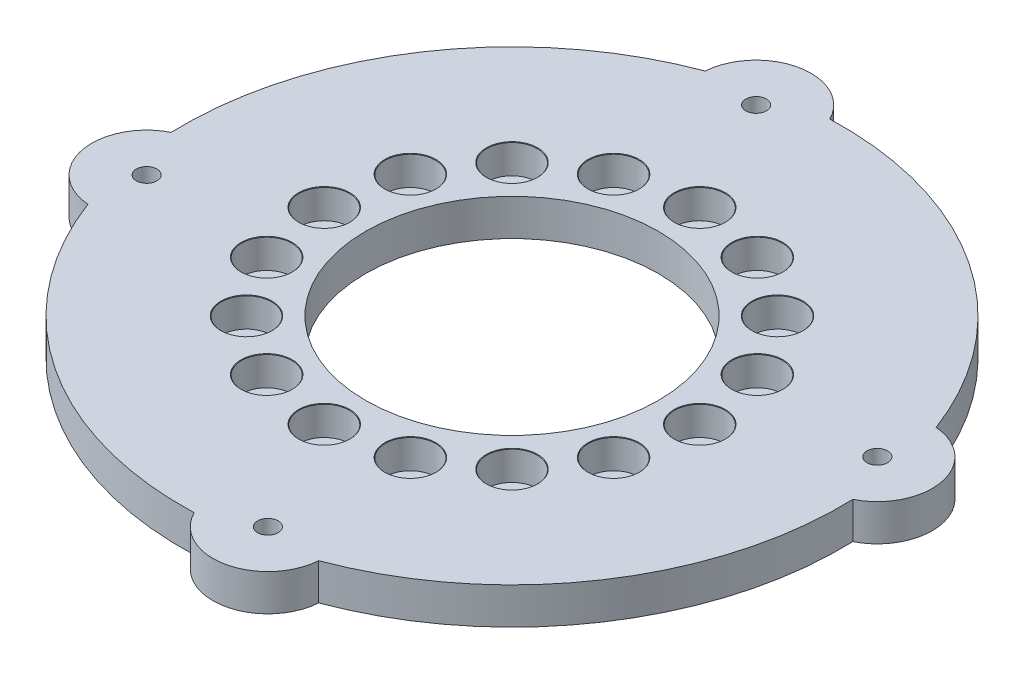
from build123d import *

# Parameters (mm, degrees)
SKETCH1_W                                            = 63.5
SKETCH1_H                                            = 12.7
CIRPATTERN1_COUNT                                    = 16
SKETCH24_R                                           = 19.05
BOSS_EXTRUDE1_DEPTH                                  = 12.7
CBORE_FOR_1_4_BINDING_HEAD_MACHINE_SCREW_D           = 7.14248
CBORE_FOR_1_4_BINDING_HEAD_MACHINE_SCREW_CBORE_D     = 14.2875
CBORE_FOR_1_4_BINDING_HEAD_MACHINE_SCREW_CBORE_DEPTH = 4.191


with BuildPart() as part:
    # Sketch1 → Revolve1 (revolve)
    with BuildSketch(Plane.XY):
        with Locations((82.55, 6.35)):
            Rectangle(SKETCH1_W, SKETCH1_H)
    revolve(axis=Axis((0, 58.205419954, 0), (0, -1, 0)))

    # Sketch20 → CBORE for 5_16 Binding Head Machine Scre (revolve, cut)
    with BuildSketch(Plane(origin=(65.1256, 12.7, 0), x_dir=(0, 0, 1), z_dir=(1, 0, 0))):
        Polygon((0, 0), (0, 12.7), (4.2164, 12.7), (4.2164, 10.16), (8.73125, 10.16), (8.73125, 0.15875), (8.89, 0), align=None)
    cbore_for_5_16_binding_head_machine_scre = revolve(axis=Axis((65.1256, 19.05, 0), (0, -1, 0)), mode=Mode.SUBTRACT)

    # CirPattern1: CBORE for 5_16 Binding Head Machine Scre ×16 about axis
    cirpattern1_axis = Axis((0, 58.205419954, 0), (0, -1, 0))
    for i in range(1, CIRPATTERN1_COUNT):
        add(cbore_for_5_16_binding_head_machine_scre.rotate(cirpattern1_axis, i * 360 / CIRPATTERN1_COUNT), mode=Mode.SUBTRACT)

    # Sketch24 → Boss-Extrude1 (add)
    with BuildSketch(Plane(origin=(0, 12.7, 0), x_dir=(1, 0, 0), z_dir=(0, 1, 0))):
        with Locations((-21.023532701, 105.692436214)):
            Circle(SKETCH24_R)
        with Locations((105.692436214, 21.023532701)):
            Circle(SKETCH24_R)
        with Locations((-105.692436214, -21.023532701)):
            Circle(SKETCH24_R)
        with Locations((21.023532701, -105.692436214)):
            Circle(SKETCH24_R)
    extrude(amount=-BOSS_EXTRUDE1_DEPTH)

    # CBORE for 1_4 Binding Head Machine Screw (through all)
    with Locations(Plane(origin=(0, 0, 0), x_dir=(-1, 0, 0), z_dir=(0, -1, 0))):
        with Locations((-21.023532701, -105.692436214), (-105.692436214, 21.023532701), (21.023532701, 105.692436214), (105.692436214, -21.023532701)):
            CounterBoreHole(CBORE_FOR_1_4_BINDING_HEAD_MACHINE_SCREW_D / 2, CBORE_FOR_1_4_BINDING_HEAD_MACHINE_SCREW_CBORE_D / 2, CBORE_FOR_1_4_BINDING_HEAD_MACHINE_SCREW_CBORE_DEPTH)


solid = part.part
